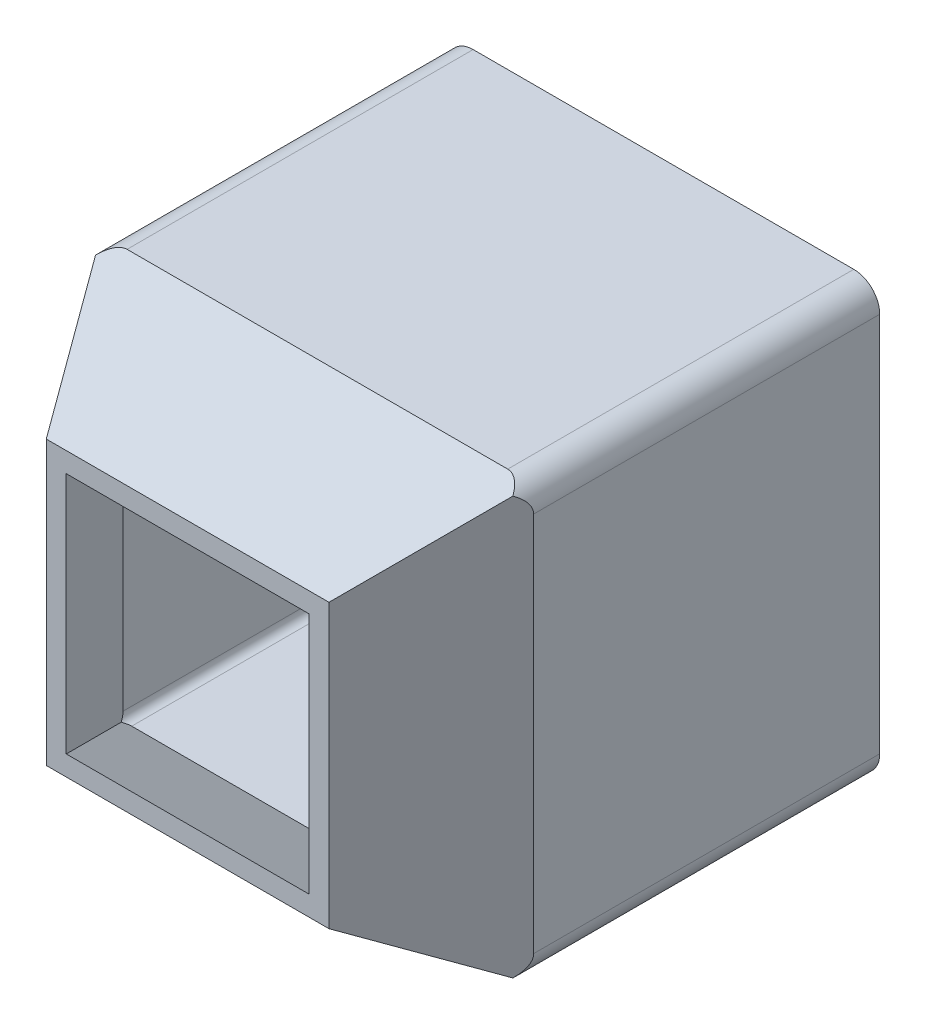
from build123d import *

# Parameters (mm, degrees)
SKETCH1_W           = 50
SKETCH1_H           = 50
BOSS_EXTRUDE1_DEPTH = 40
SKETCH2_W           = 50
SKETCH2_H           = 50
BOSS_EXTRUDE2_DEPTH = 15
BOSS_EXTRUDE2_TAPER = 30
FILLET1_R           = 3
SHELL1_T            = -2


with BuildPart() as part:
    # Sketch1 → Boss-Extrude1 (new body)
    with BuildSketch(Plane.XY):
        with Locations((5, 32.5)):
            Rectangle(SKETCH1_W, SKETCH1_H)
    extrude(amount=-BOSS_EXTRUDE1_DEPTH)

    # Sketch2 → Boss-Extrude2 (add)
    with BuildSketch(Plane.XY):
        with Locations((5, 32.5)):
            Rectangle(SKETCH2_W, SKETCH2_H)
    extrude(amount=BOSS_EXTRUDE2_DEPTH, taper=BOSS_EXTRUDE2_TAPER)

    # Fillet1
    fillet1_edges = [part.edges().sort_by_distance(p)[0] for p in [
        (30, 7.5, -20),
        (-20, 7.5, -20),
        (-20, 57.5, -20),
        (30, 57.5, -20),
    ]]
    fillet(fillet1_edges, radius=FILLET1_R)

    # Shell1
    shell1_openings = [part.faces().sort_by_distance(p)[0] for p in [
        (5, 32.5, -40),
        (5, 32.5, 15),
    ]]
    offset(amount=SHELL1_T, openings=shell1_openings, kind=Kind.INTERSECTION)


solid = part.part
